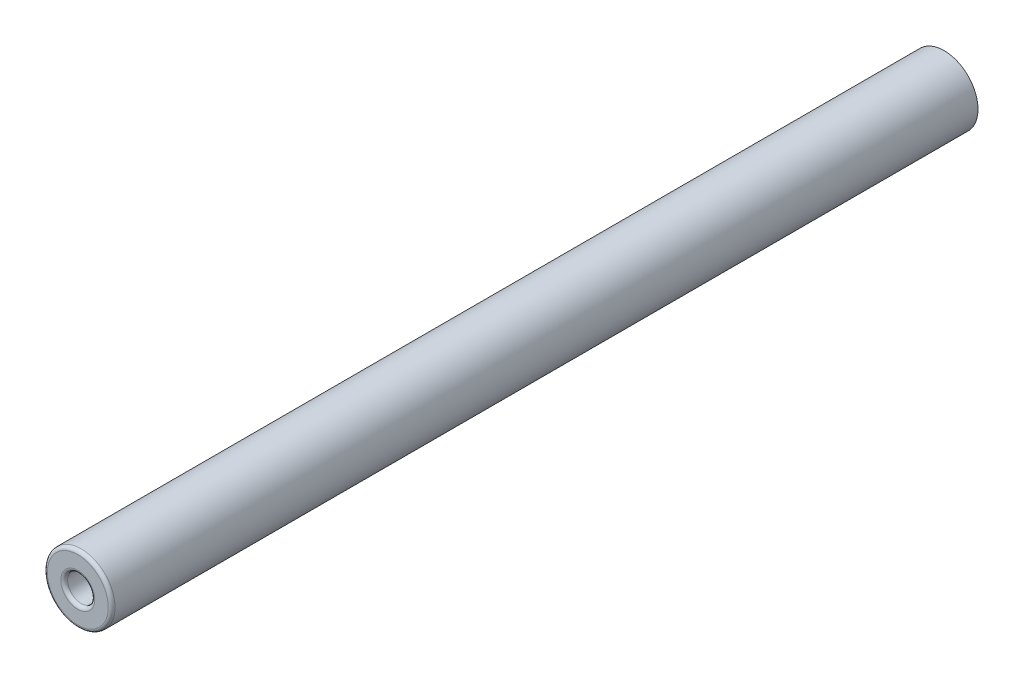
from build123d import *

# Parameters (mm, degrees)
SKETCH1_R      = 2.5
EXTRUDE1_DEPTH = 64
SKETCH2_R      = 1
ICE1_DEPTH     = 10
FILLET1_R      = 0.25


with BuildPart() as part:
    # Sketch1 → Extrude1 (new body)
    with BuildSketch(Plane.XY):
        Circle(SKETCH1_R)
    extrude(amount=EXTRUDE1_DEPTH)

    # Sketch2 → ICE1 (cut)
    with BuildSketch(Plane.XY.offset(64)):
        Circle(SKETCH2_R)
    extrude(amount=-ICE1_DEPTH, mode=Mode.SUBTRACT)

    # Fillet1
    fillet1_edges = [part.edges().sort_by_distance(p)[0] for p in [
        (-2.5, 0, 64),
        (-1, 0, 64),
    ]]
    fillet(fillet1_edges, radius=FILLET1_R)


solid = part.part
